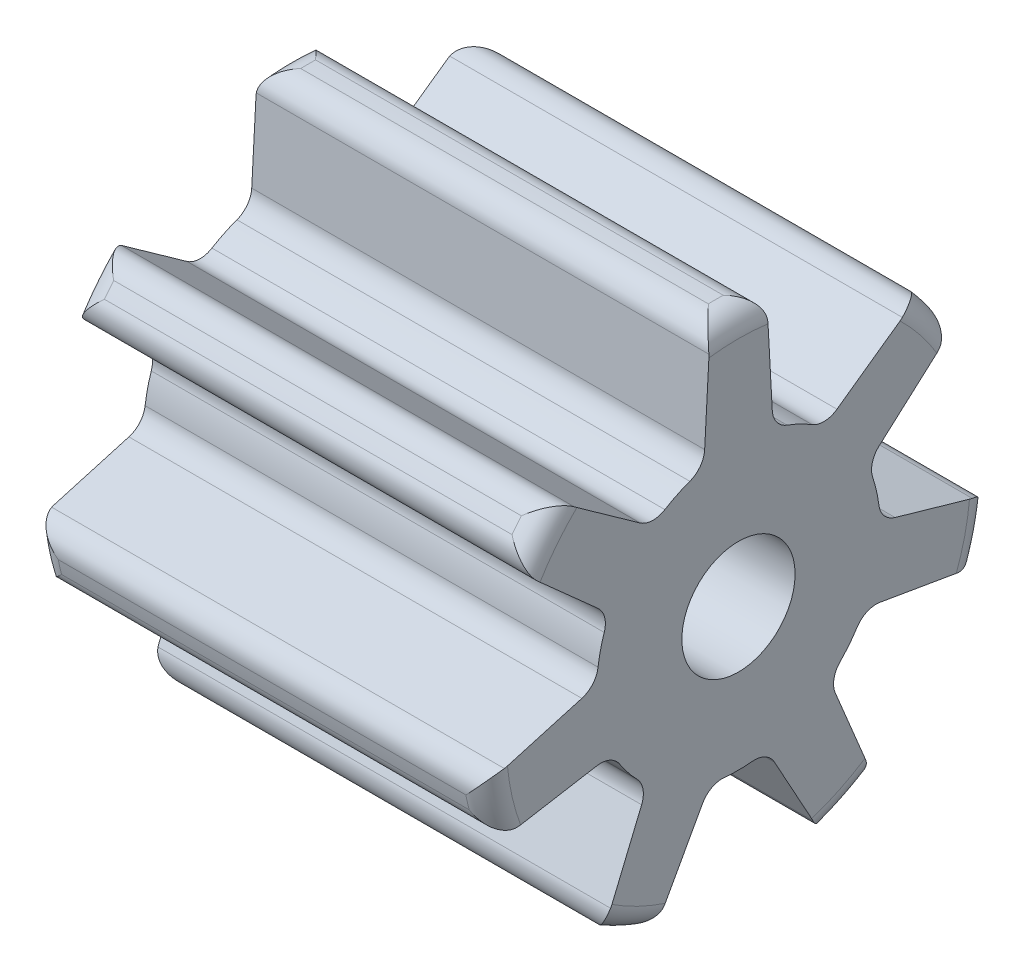
from build123d import *

# Parameters (mm, degrees)
SKETCH3_R           = 2.25
SKETCH3_R_2         = 0.5
BOSS_EXTRUDE1_DEPTH = 2
CUT_EXTRUDE2_DEPTH  = 2
FILLET1_R           = 0.2


with BuildPart() as part:
    # Sketch3 → Boss-Extrude1 (new body, symmetric)
    with BuildSketch(Plane(origin=(0, 0, 0), x_dir=(0, 0, -1), z_dir=(1, 0, 0))):
        Circle(SKETCH3_R)
        Circle(SKETCH3_R_2, mode=Mode.SUBTRACT)
    extrude(amount=BOSS_EXTRUDE1_DEPTH, both=True)

    # Sketch4 → Cut-Extrude2 (cut, symmetric)
    with BuildSketch(Plane(origin=(0, 0, 0), x_dir=(0, 0, -1), z_dir=(1, 0, 0))):
        with BuildLine():
            Line((2.235635318, -0.253839957), (1.383325928, -0.009515205))
            ThreePointArc((1.383325928, -0.009515205), (1.286634966, 0.052527484), (1.240033271, 0.157535672))
            ThreePointArc((1.240033271, 0.157535672), (1.21865989, 0.278151167), (1.185583538, 0.396095536))
            ThreePointArc((1.185583538, 0.396095536), (1.18200887, 0.510924362), (1.242205103, 0.60877553))
            Line((1.242205103, 0.60877553), (1.904100792, 1.19870771))
            ThreePointArc((1.904100792, 1.19870771), (2.193587802, 0.500672101), (2.235635318, -0.253839957))
        make_face()
        with BuildLine():
            Line((1.195435752, -1.906156699), (0.855050322, -1.087460395))
            ThreePointArc((0.855050322, -1.087460395), (0.843271421, -0.973181372), (0.896314446, -0.871275165))
            ThreePointArc((0.896314446, -0.871275165), (0.977289353, -0.779362252), (1.048879206, -0.679965008))
            ThreePointArc((1.048879206, -0.679965008), (1.136427227, -0.605575618), (1.250462088, -0.591629723))
            Line((1.250462088, -0.591629723), (2.124374851, -0.741303913))
            ThreePointArc((2.124374851, -0.741303913), (1.759120836, -1.402852054), (1.195435752, -1.906156699))
        make_face()
        with BuildLine():
            Line((-0.744951318, -2.123098569), (-0.317095616, -1.346525727))
            ThreePointArc((-0.317095616, -1.346525727), (-0.235092704, -1.266064806), (-0.122347438, -1.243998032))
            ThreePointArc((-0.122347438, -1.243998032), (0, -1.25), (0.122347438, -1.243998032))
            ThreePointArc((0.122347438, -1.243998032), (0.235092704, -1.266064806), (0.317095616, -1.346525727))
            Line((0.317095616, -1.346525727), (0.744951318, -2.123098569))
            ThreePointArc((0.744951318, -2.123098569), (0, -2.25), (-0.744951318, -2.123098569))
        make_face()
        with BuildLine():
            Line((-2.124374851, -0.741303913), (-1.250462088, -0.591629723))
            ThreePointArc((-1.250462088, -0.591629723), (-1.136427227, -0.605575618), (-1.048879206, -0.679965008))
            ThreePointArc((-1.048879206, -0.679965008), (-0.977289353, -0.779362252), (-0.896314446, -0.871275165))
            ThreePointArc((-0.896314446, -0.871275165), (-0.843271421, -0.973181372), (-0.855050322, -1.087460395))
            Line((-0.855050322, -1.087460395), (-1.195435752, -1.906156699))
            ThreePointArc((-1.195435752, -1.906156699), (-1.759120836, -1.402852054), (-2.124374851, -0.741303913))
        make_face()
        with BuildLine():
            Line((-1.904100792, 1.19870771), (-1.242205103, 0.60877553))
            ThreePointArc((-1.242205103, 0.60877553), (-1.18200887, 0.510924362), (-1.185583538, 0.396095536))
            ThreePointArc((-1.185583538, 0.396095536), (-1.21865989, 0.278151167), (-1.240033271, 0.157535672))
            ThreePointArc((-1.240033271, 0.157535672), (-1.286634966, 0.052527484), (-1.383325928, -0.009515205))
            Line((-1.383325928, -0.009515205), (-2.235635318, -0.253839957))
            ThreePointArc((-2.235635318, -0.253839957), (-2.193587802, 0.500672101), (-1.904100792, 1.19870771))
        make_face()
        with BuildLine():
            Line((-0.25, 2.236067977), (-0.298542339, 1.350760392))
            ThreePointArc((-0.298542339, 1.350760392), (-0.337513725, 1.242687876), (-0.429519285, 1.173888063))
            ThreePointArc((-0.429519285, 1.173888063), (-0.542354674, 1.126211085), (-0.64998175, 1.067718935))
            ThreePointArc((-0.64998175, 1.067718935), (-0.761136139, 1.038682073), (-0.869928896, 1.075595128))
            Line((-0.869928896, 1.075595128), (-1.592355891, 1.589623451))
            ThreePointArc((-1.592355891, 1.589623451), (-0.976238413, 2.027179953), (-0.25, 2.236067977))
        make_face()
        with BuildLine():
            Line((0.25, 2.236067977), (0.298542339, 1.350760392))
            ThreePointArc((0.298542339, 1.350760392), (0.337513725, 1.242687876), (0.429519285, 1.173888063))
            ThreePointArc((0.429519285, 1.173888063), (0.542354674, 1.126211085), (0.64998175, 1.067718935))
            ThreePointArc((0.64998175, 1.067718935), (0.761136139, 1.038682073), (0.869928896, 1.075595128))
            Line((0.869928896, 1.075595128), (1.592355891, 1.589623451))
            ThreePointArc((1.592355891, 1.589623451), (0.976238413, 2.027179953), (0.25, 2.236067977))
        make_face()
    extrude(amount=CUT_EXTRUDE2_DEPTH, both=True, mode=Mode.SUBTRACT)

    # Fillet1
    fillet1_edges = [part.edges().sort_by_distance(p)[0] for p in [
        (2, 2.25, 0),
        (2, 1.402852054, 1.759120836),
        (0, 2.236067977, -0.25),
        (0, 1.589623451, -1.592355891),
        (2, -0.500672101, 2.193587802),
        (2, -2.027179953, 0.976238413),
        (2, -2.027179953, -0.976238413),
        (2, -0.500672101, -2.193587802),
        (-2, 2.25, 0),
        (-2, 1.402852054, 1.759120836),
        (-2, -0.500672101, 2.193587802),
        (-2, -2.027179953, 0.976238413),
        (-2, -2.027179953, -0.976238413),
        (-2, -0.500672101, -2.193587802),
        (-2, 1.402852054, -1.759120836),
        (2, 1.402852054, -1.759120836),
        (0, 1.19870771, -1.904100792),
        (0, -0.253839957, -2.235635318),
        (0, -0.741303913, -2.124374851),
        (0, -1.906156699, -1.195435752),
        (0, -2.123098569, -0.744951318),
        (0, -2.123098569, 0.744951318),
        (0, -1.906156699, 1.195435752),
        (0, -0.741303913, 2.124374851),
        (0, 1.589623451, 1.592355891),
        (0, 2.236067977, 0.25),
        (0, -0.253839957, 2.235635318),
        (0, 1.19870771, 1.904100792),
    ]]
    fillet(fillet1_edges, radius=FILLET1_R)


solid = part.part
